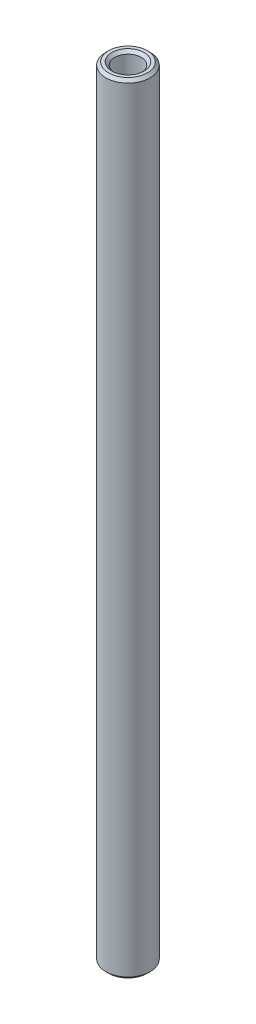
from build123d import *

# Parameters (mm, degrees)
SKETCH1_R           = 1.984375
SKETCH1_R_2         = 1.190625
BOSS_EXTRUDE1_DEPTH = 34.925
CHAMFER1_SIZE       = 0.254


with BuildPart() as part:
    # Sketch1 → Boss-Extrude1 (new body, symmetric)
    with BuildSketch(Plane(origin=(0, 0, 0), x_dir=(1, 0, 0), z_dir=(0, 1, 0))):
        Circle(SKETCH1_R)
        Circle(SKETCH1_R_2, mode=Mode.SUBTRACT)
    extrude(amount=BOSS_EXTRUDE1_DEPTH, both=True)

    # Chamfer1
    chamfer1_edges = [part.edges().sort_by_distance(p)[0] for p in [
        (-1.984375, -34.925, 0),
        (-1.984375, 34.925, 0),
        (-1.190625, -34.925, 0),
        (-1.190625, 34.925, 0),
    ]]
    chamfer(chamfer1_edges, length=CHAMFER1_SIZE)


solid = part.part
